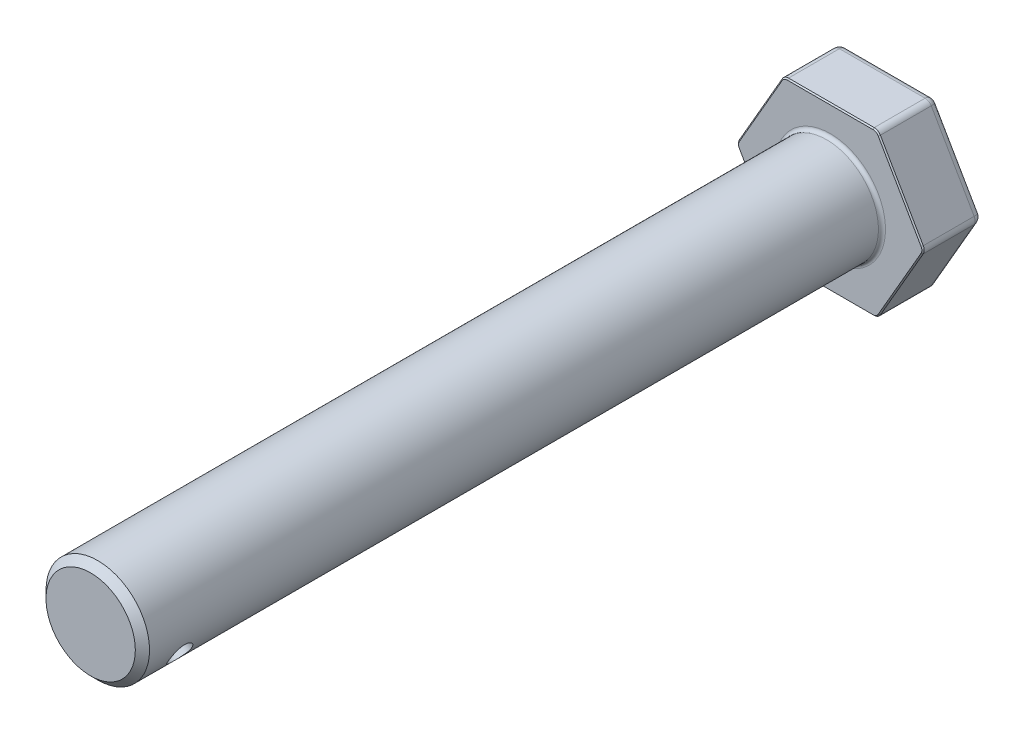
from build123d import *

# Parameters (mm, degrees)
SHANK_DIAMETER_R      = 5.55625
SHANK_DEPTH           = 79.375
HEAD_DEPTH            = 6.35
SKETCH1_R             = 1.27
SHANK_HOLE_DEPTH      = 22.828125
SHANK_HOLE_DEPTH_BACK = 5.365625
FILLET1_R             = 0.762
FILLET2_R             = 0.762
CHAMFER1_SIZE         = 0.762
CHAMFER2_SIZE         = 0.127
FILLET4_R             = 0.381


with BuildPart() as part:
    # Shank_Diameter → Shank (new body)
    with BuildSketch(Plane.XY):
        Circle(SHANK_DIAMETER_R)
    extrude(amount=SHANK_DEPTH)

    # Hex 2 → Head (add)
    with BuildSketch(Plane(origin=(0, 0, 0), x_dir=(-1, 0, 0), z_dir=(0, 0, -1))):
        Polygon((-5.040989538, 8.73125), (5.040989538, 8.73125), (10.081979076, 0), (5.040989538, -8.73125), (-5.040989538, -8.73125), (-10.081979076, 0), align=None)
    extrude(amount=HEAD_DEPTH)

    # Sketch1 → Shank_Hole (cut, two sides)
    with BuildSketch(Plane(origin=(-8.305880657, 3.0762927, 0), x_dir=(0, 0, -1), z_dir=(0.866025404, -0.5, 0))) as shank_hole_sk:
        with Locations((-74.6125, 1.4887927)):
            Circle(SKETCH1_R)
    extrude(amount=SHANK_HOLE_DEPTH, mode=Mode.SUBTRACT)
    extrude(shank_hole_sk.sketch, amount=-SHANK_HOLE_DEPTH_BACK, mode=Mode.SUBTRACT)

    # Fillet1
    fillet1_edges = [part.edges().sort_by_distance(p)[0] for p in [
        (5.040989538, 8.73125, -3.175),
        (10.081979076, 0, -3.175),
        (5.040989538, -8.73125, -3.175),
        (-5.040989538, -8.73125, -3.175),
        (-10.081979076, 0, -3.175),
        (-5.040989538, 8.73125, -3.175),
    ]]
    fillet(fillet1_edges, radius=FILLET1_R)

    # Fillet2
    fillet2_edges = [part.edges().sort_by_distance(p)[0] for p in [
        (0, 8.73125, -6.35),
        (-7.561484307, 4.365625, -6.35),
        (7.561484307, 4.365625, -6.35),
        (7.561484307, -4.365625, -6.35),
        (0, -8.73125, -6.35),
        (-7.561484307, -4.365625, -6.35),
    ]]
    fillet(fillet2_edges, radius=FILLET2_R)

    # Chamfer1
    chamfer1_edges = [part.edges().sort_by_distance(p)[0] for p in [
        (-5.55625, 0, 79.375),
    ]]
    chamfer(chamfer1_edges, length=CHAMFER1_SIZE)

    # Chamfer2
    chamfer2_edges = [part.edges().sort_by_distance(p)[0] for p in [
        (0, 8.73125, 0),
        (7.561484307, 4.365625, 0),
        (-7.561484307, 4.365625, 0),
        (-7.561484307, -4.365625, 0),
        (0, -8.73125, 0),
        (7.561484307, -4.365625, 0),
        (-4.982048633, -8.629161358, 0),
        (4.982048633, -8.629161358, 0),
        (-9.964097265, 0, 0),
        (9.964097265, 0, 0),
        (4.982048633, 8.629161358, 0),
        (-4.982048633, 8.629161358, 0),
    ]]
    chamfer(chamfer2_edges, length=CHAMFER2_SIZE)

    # Fillet4
    fillet4_edges = [part.edges().sort_by_distance(p)[0] for p in [
        (-5.55625, 0, 0),
    ]]
    fillet(fillet4_edges, radius=FILLET4_R)


solid = part.part
